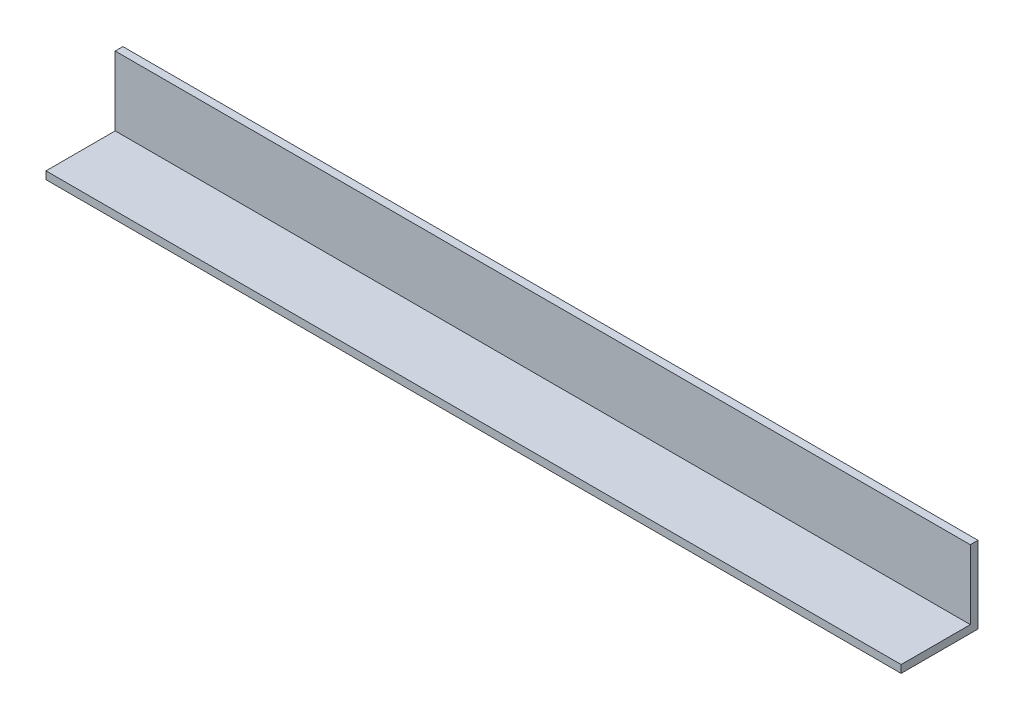
from build123d import *

# Parameters (mm, degrees)
SKETCH1_W           = 445
SKETCH1_H           = 40
BOSS_EXTRUDE1_DEPTH = 4
SKETCH2_W           = 445
SKETCH2_H           = 4
BOSS_EXTRUDE2_DEPTH = 36


with BuildPart() as part:
    # Sketch1 → Boss-Extrude1 (new body)
    with BuildSketch(Plane(origin=(0, 0, 0), x_dir=(1, 0, 0), z_dir=(0, 1, 0))):
        Rectangle(SKETCH1_W, SKETCH1_H)
    extrude(amount=BOSS_EXTRUDE1_DEPTH)

    # Sketch2 → Boss-Extrude2 (add)
    with BuildSketch(Plane(origin=(0, 4, 0), x_dir=(1, 0, 0), z_dir=(0, 1, 0))):
        with Locations((0, 18)):
            Rectangle(SKETCH2_W, SKETCH2_H)
    extrude(amount=BOSS_EXTRUDE2_DEPTH)


solid = part.part
